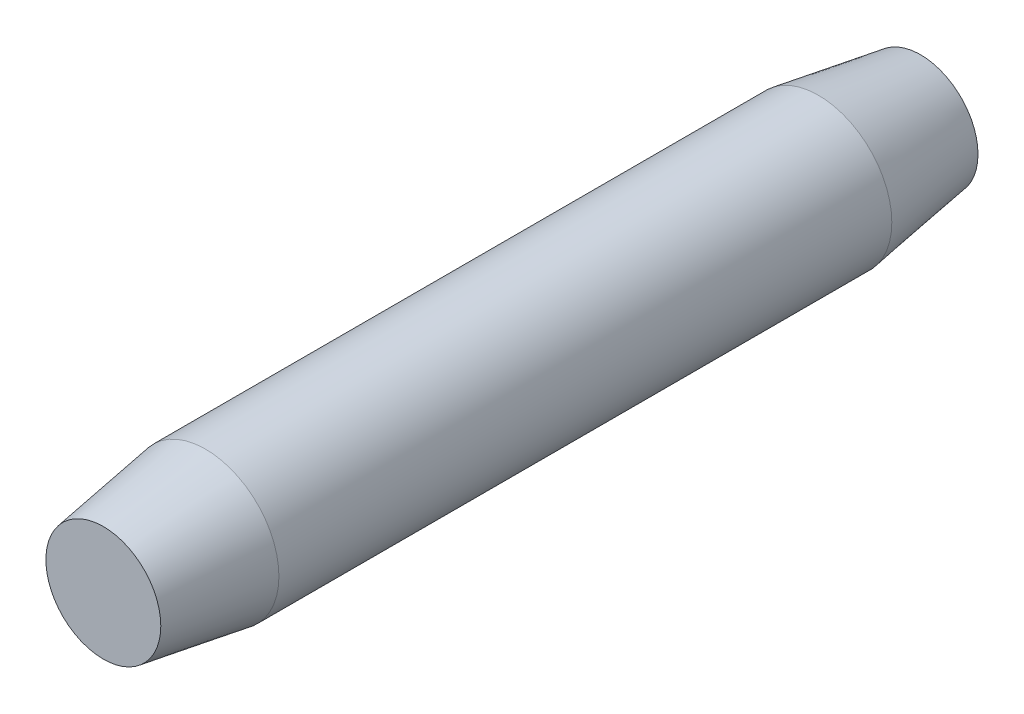
from build123d import *

# Parameters (mm, degrees)
SKETCH1_R           = 18.25625
BOSS_EXTRUDE1_DEPTH = 101.6
CHAMFER1_SIZE       = 25.4
CHAMFER1_SIZE2      = 3.96875
CHAMFER2_SIZE       = 3.96875
CHAMFER2_SIZE2      = 25.4


with BuildPart() as part:
    # Sketch1 → Boss-Extrude1 (new body, symmetric)
    with BuildSketch(Plane.XY):
        Circle(SKETCH1_R)
    extrude(amount=BOSS_EXTRUDE1_DEPTH, both=True)

    # Chamfer1
    chamfer1_edges = [part.edges().sort_by_distance(p)[0] for p in [
        (-18.25625, 0, 101.6),
    ]]
    chamfer1_side = [part.faces().sort_by_distance(p)[0] for p in [
        (-18.25625, 0, 0),
    ]]
    chamfer(chamfer1_edges, length=CHAMFER1_SIZE, length2=CHAMFER1_SIZE2, reference=chamfer1_side[0])

    # Chamfer2
    chamfer2_edges = [part.edges().sort_by_distance(p)[0] for p in [
        (-18.25625, 0, -101.6),
    ]]
    chamfer2_side = [part.faces().sort_by_distance(p)[0] for p in [
        (0, 0, -101.6),
    ]]
    chamfer(chamfer2_edges, length=CHAMFER2_SIZE, length2=CHAMFER2_SIZE2, reference=chamfer2_side[0])


solid = part.part
